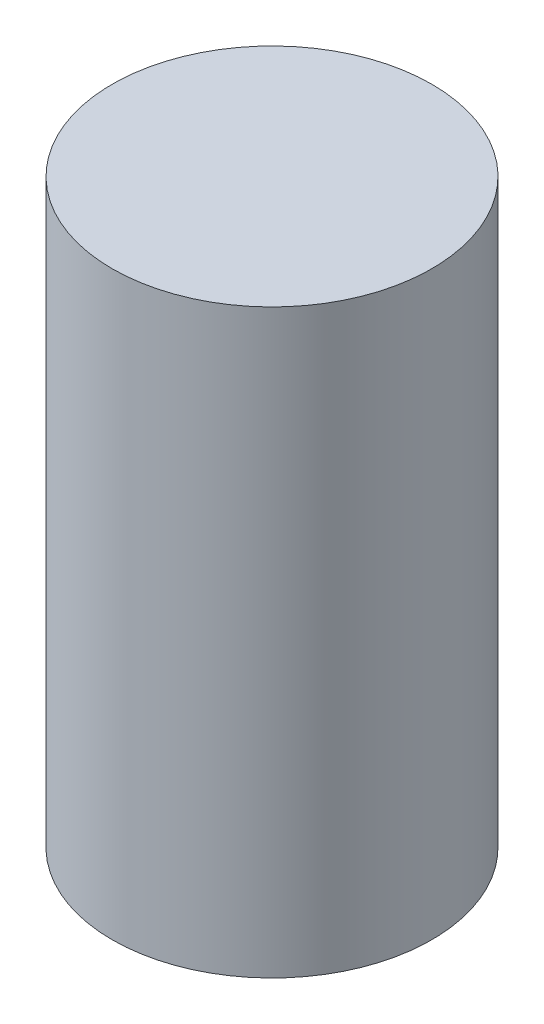
from build123d import *

# Parameters (mm, degrees)
SKETCH1_R           = 69.85
BOSS_EXTRUDE1_DEPTH = 254


with BuildPart() as part:
    # Sketch1 → Boss-Extrude1 (new body)
    with BuildSketch(Plane(origin=(0, 0, 0), x_dir=(1, 0, 0), z_dir=(0, 1, 0))):
        Circle(SKETCH1_R)
    extrude(amount=BOSS_EXTRUDE1_DEPTH)


solid = part.part
